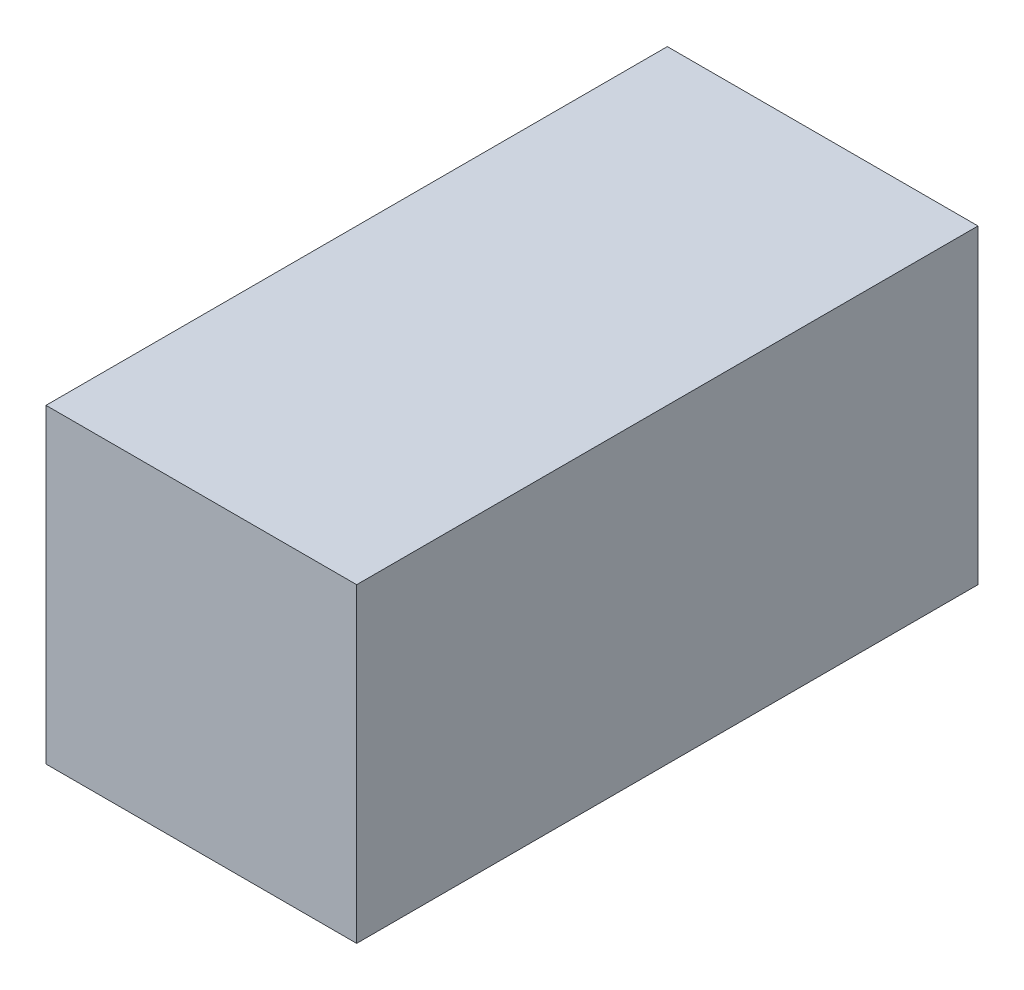
from build123d import *

# Parameters (mm, degrees)
SKETCH1_W           = 20
SKETCH1_H           = 20
BOSS_EXTRUDE1_DEPTH = 40


with BuildPart() as part:
    # Sketch1 → Boss-Extrude1 (new body)
    with BuildSketch(Plane.XY):
        with Locations((10, 10)):
            Rectangle(SKETCH1_W, SKETCH1_H)
    extrude(amount=BOSS_EXTRUDE1_DEPTH)


solid = part.part
